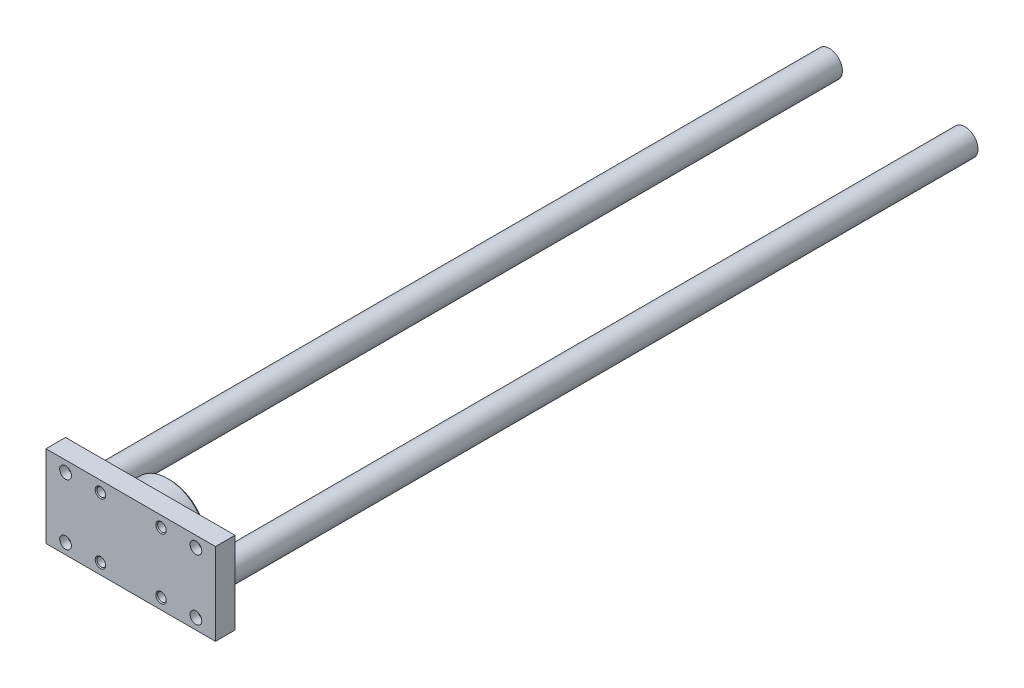
from build123d import *

# Parameters (mm, degrees)
SKETCH1_W            = 130
SKETCH1_H            = 63
BOSS_EXTRUDE1_DEPTH  = 15
LPATTERN1_COUNT      = 2
LPATTERN1_PITCH      = 46.5
LPATTERN1_COUNT_DIR2 = 2
LPATTERN1_PITCH_DIR2 = 46.5
LPATTERN2_COUNT      = 2
LPATTERN2_PITCH      = 100
LPATTERN2_COUNT_DIR2 = 2
LPATTERN2_PITCH_DIR2 = 46.5
SKETCH6_R            = 10
BOSS_EXTRUDE2_DEPTH  = 588
SKETCH7_R            = 10
BOSS_EXTRUDE3_DEPTH  = 588
SKETCH10_W           = 40
SKETCH10_H           = 40
SKETCH10_W_2         = 18
SKETCH10_H_2         = 30
CUT_EXTRUDE1_DEPTH   = 10


with BuildPart() as part:
    # Sketch1 → Boss-Extrude1 (new body)
    with BuildSketch(Plane.XY.offset(89)):
        Rectangle(SKETCH1_W, SKETCH1_H)
    extrude(amount=-BOSS_EXTRUDE1_DEPTH)

    # Sketch2 → Cut-Revolve1 (revolve, cut)
    with BuildSketch(Plane(origin=(23.25, 0, 0), x_dir=(0, 0, -1), z_dir=(1, 0, 0))):
        Polygon((-89, 23.25), (-89, 27.25), (-88.3235, 26.5735), (-74.6765, 26.5735), (-74, 27.25), (-74, 23.25), align=None)
    cut_revolve1 = revolve(axis=Axis((23.25, 23.25, 74), (0, 0, 1)), mode=Mode.SUBTRACT)

    # LPattern1: Cut-Revolve1 2 × 2
    with Locations(*[(-i * LPATTERN1_PITCH, -j * LPATTERN1_PITCH_DIR2, 0) for i in range(LPATTERN1_COUNT) for j in range(LPATTERN1_COUNT_DIR2) if (i, j) != (0, 0)]):
        add(cut_revolve1, mode=Mode.SUBTRACT)

    # Sketch4 → Cut-Revolve2 (revolve, cut)
    with BuildSketch(Plane(origin=(50, 0, 0), x_dir=(0, 0, -1), z_dir=(1, 0, 0))):
        Polygon((-89, 23.25), (-89, 27.75), (-83, 27.75), (-83, 30.75), (-74, 30.75), (-74, 23.25), align=None)
    cut_revolve2 = revolve(axis=Axis((50, 23.25, 74), (0, 0, 1)), mode=Mode.SUBTRACT)

    # LPattern2: Cut-Revolve2 2 × 2
    with Locations(*[(-i * LPATTERN2_PITCH, -j * LPATTERN2_PITCH_DIR2, 0) for i in range(LPATTERN2_COUNT) for j in range(LPATTERN2_COUNT_DIR2) if (i, j) != (0, 0)]):
        add(cut_revolve2, mode=Mode.SUBTRACT)

    # Sketch6 → Boss-Extrude2 (add)
    with BuildSketch(Plane.XY.offset(89)):
        with Locations((-52, 0)):
            Circle(SKETCH6_R)
    extrude(amount=-BOSS_EXTRUDE2_DEPTH)

    # Sketch7 → Boss-Extrude3 (add)
    with BuildSketch(Plane.XY.offset(89)):
        with Locations((52, 0)):
            Circle(SKETCH7_R)
    extrude(amount=-BOSS_EXTRUDE3_DEPTH)

    # Sketch8 → Revolve1 (revolve)
    with BuildSketch(Plane(origin=(0, 0, 0), x_dir=(0, 0, -1), z_dir=(1, 0, 0))):
        Polygon((-74, 0), (-74, 30), (-60.6, 30), (-59, 28.4), (-59, 11), (-50, 11), (-49, 10), (-49, 0), align=None)
    revolve(axis=Axis((0, 0, 49), (0, 0, 1)))

    # Sketch9 → Cut-Revolve3 (revolve, cut)
    with BuildSketch(Plane(origin=(0, 0, 0), x_dir=(0, 0, -1), z_dir=(1, 0, 0))):
        Polygon((-74, 0), (-74, 7.188), (-49.812, 7.188), (-49, 8), (-49, 0), align=None)
    revolve(axis=Axis((0, 0, 49), (0, 0, 1)), mode=Mode.SUBTRACT)

    # Sketch10 → Cut-Extrude1 (cut)
    with BuildSketch(Plane.XY.offset(49)):
        Rectangle(SKETCH10_W, SKETCH10_H)
        Rectangle(SKETCH10_W_2, SKETCH10_H_2, mode=Mode.SUBTRACT)
    extrude(amount=CUT_EXTRUDE1_DEPTH, mode=Mode.SUBTRACT)


solid = part.part
